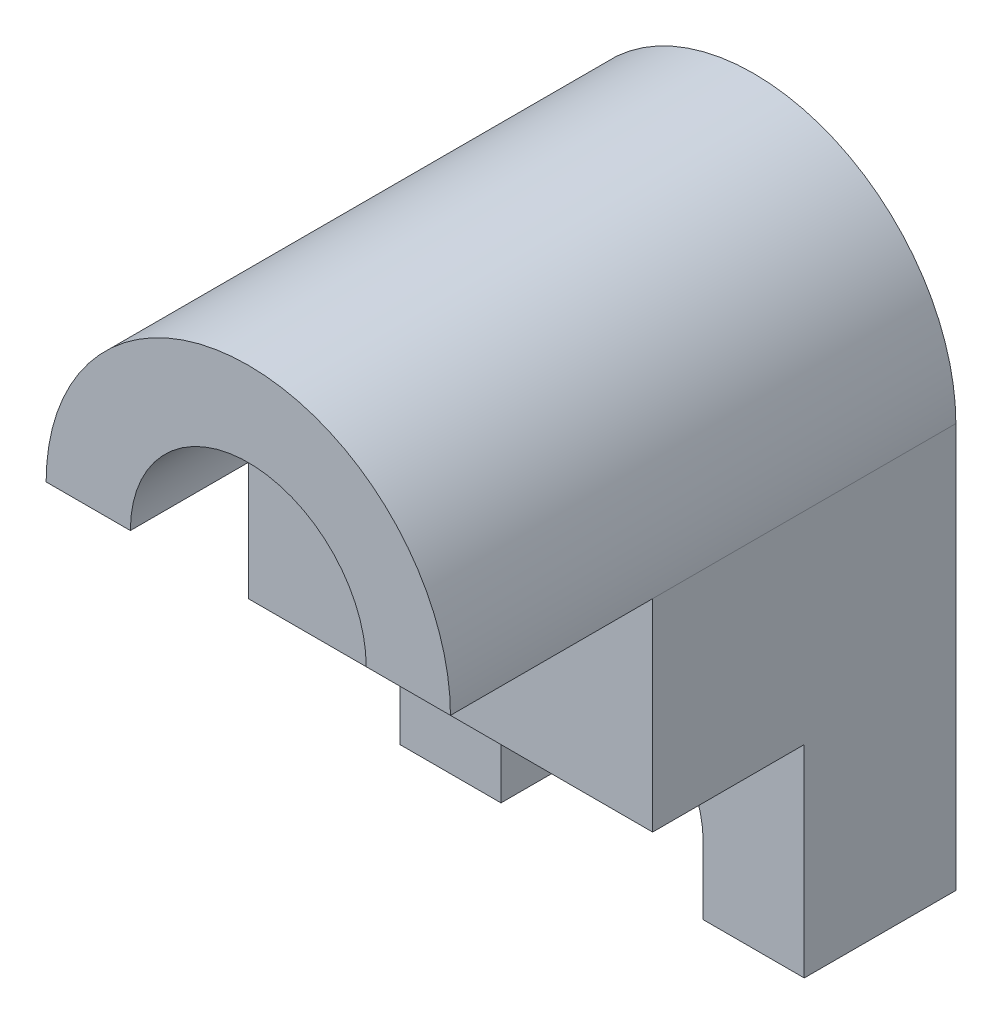
from build123d import *

# Parameters (mm, degrees)
SKETCH1_R           = 3.5
BOSS_EXTRUDE1_DEPTH = 15
CUT_EXTRUDE1_DEPTH  = 15


with BuildPart() as part:
    # Sketch1 → Boss-Extrude1 (new body)
    with BuildSketch(Plane.XY):
        with BuildLine():
            Line((-6, 6), (-6, -6))
            Line((-6, -6), (-3, -6))
            Line((-3, -6), (-3, -3.996197441))
            ThreePointArc((-3, -3.996197441), (0, -0.996197441), (3, -3.996197441))
            Line((3, -3.996197441), (3, -6))
            Line((3, -6), (6, -6))
            Line((6, -6), (6, 6))
            ThreePointArc((6, 6), (0, 12), (-6, 6))
        make_face()
        with Locations((0, 6)):
            Circle(SKETCH1_R, mode=Mode.SUBTRACT)
    extrude(amount=BOSS_EXTRUDE1_DEPTH)

    # Sketch2 → Cut-Extrude1 (cut)
    with BuildSketch(Plane.ZY.offset(6)):
        Polygon((4.5, -6), (4.5, 0), (9, 0), (9, 6), (15, 6), (15, -6), align=None)
    extrude(amount=-CUT_EXTRUDE1_DEPTH, mode=Mode.SUBTRACT)


solid = part.part
